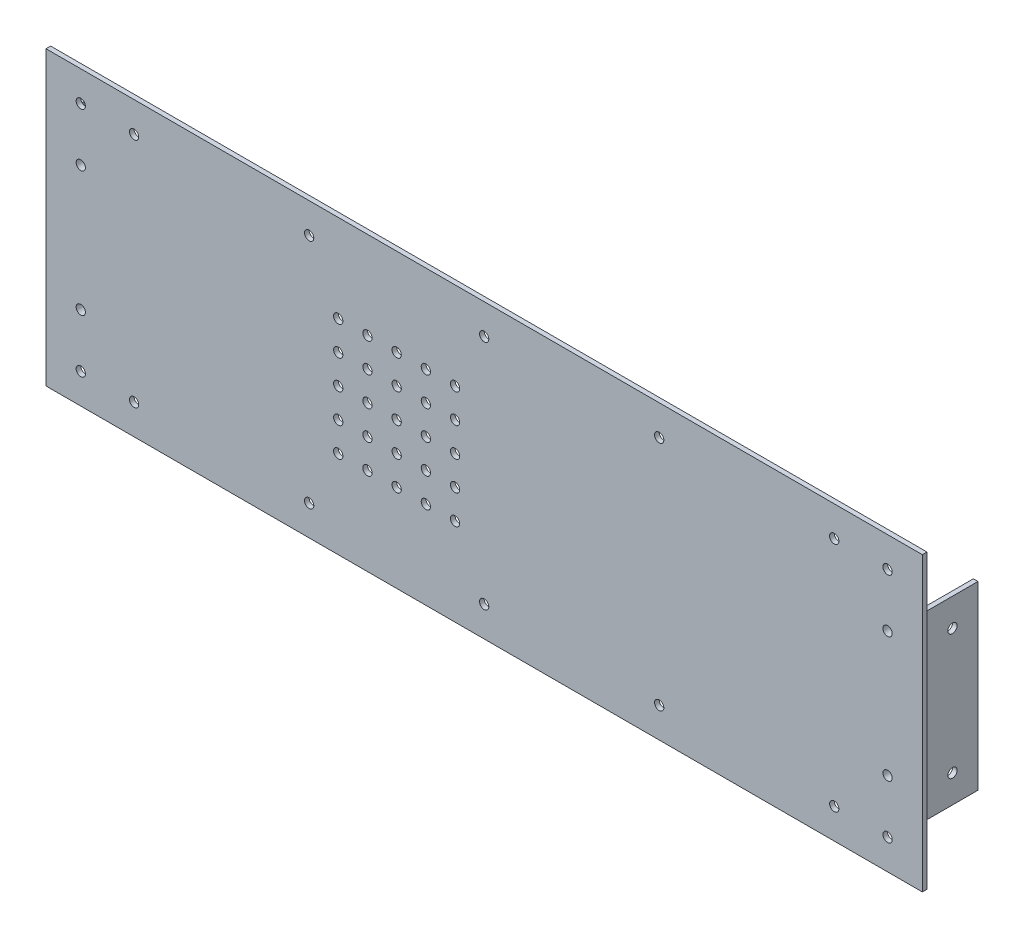
from build123d import *

# Parameters (mm, degrees)
ESQUISSE1_W                  = 300
ESQUISSE1_H                  = 100
BOSS_EXTRU_1_DEPTH           = 1.5875
ESQUISSE2_W                  = 19.05
ESQUISSE2_H                  = 61.9
BOSS_EXTRU_2_DEPTH           = 1.5875
ESQUISSE3_W                  = 1.5875
ESQUISSE3_H                  = 61.9
BOSS_EXTRU_3_DEPTH           = 17.4625
ENL_V_MAT_EXTRU_1_REACH      = 5.175
ESQUISSE4_R                  = 1.5875
ENL_V_MAT_EXTRU_2_REACH      = 22.637
ESQUISSE5_R                  = 1.5875
ESQUISSE7_R                  = 1.5875
ENL_V_MAT_EXTRU_4_DEPTH      = 297.825
ENL_V_MAT_EXTRU_4_DEPTH_BACK = 4.175
ESQUISSE8_R                  = 1.5875
ENL_V_MAT_EXTRU_5_DEPTH      = 1.5875


with BuildPart() as part:
    # Esquisse1 → Boss.-Extru.1 (new body)
    with BuildSketch(Plane.XY):
        with Locations((29.89832913, 31.147540984)):
            Rectangle(ESQUISSE1_W, ESQUISSE1_H)
    extrude(amount=BOSS_EXTRU_1_DEPTH)

    # Esquisse2 → Boss.-Extru.2 (add)
    with BuildSketch(Plane(origin=(0, 0, 0), x_dir=(-1, 0, 0), z_dir=(0, 0, -1))):
        with Locations((108.98917087, 31.147540984)):
            Rectangle(ESQUISSE2_W, ESQUISSE2_H)
        with Locations((-168.78582913, 31.147540984)):
            Rectangle(ESQUISSE2_W, ESQUISSE2_H)
    extrude(amount=BOSS_EXTRU_2_DEPTH)

    # Esquisse3 → Boss.-Extru.3 (add)
    with BuildSketch(Plane(origin=(0, 0, -1.5875), x_dir=(-1, 0, 0), z_dir=(0, 0, -1))):
        with Locations((-177.51707913, 31.147540984)):
            Rectangle(ESQUISSE3_W, ESQUISSE3_H)
        with Locations((117.72042087, 31.147540984)):
            Rectangle(ESQUISSE3_W, ESQUISSE3_H)
    extrude(amount=BOSS_EXTRU_3_DEPTH)

    # Esquisse4 → Enlèv. mat.-Extru.1 (cut, up to next)
    with BuildSketch(Plane(origin=(0, 0, -1.5875), x_dir=(-1, 0, 0), z_dir=(0, 0, -1)), mode=Mode.PRIVATE) as enl_v_mat_extru_1_sk1:
        with Locations((-167.99207913, 52.572540984)):
            Circle(ESQUISSE4_R)
    enl_v_mat_extru_1_tool1 = extrude(enl_v_mat_extru_1_sk1.sketch, amount=-ENL_V_MAT_EXTRU_1_REACH, mode=Mode.PRIVATE) & part.part
    add(enl_v_mat_extru_1_tool1.solids().sort_by_distance((167.992079, 52.572541, -1.5875))[0], mode=Mode.SUBTRACT)
    # Esquisse4 → Enlèv. mat.-Extru.1 (cut, up to next)
    with BuildSketch(Plane(origin=(0, 0, -1.5875), x_dir=(-1, 0, 0), z_dir=(0, 0, -1)), mode=Mode.PRIVATE) as enl_v_mat_extru_1_sk2:
        with Locations((-167.99207913, 9.722540984)):
            Circle(ESQUISSE4_R)
    enl_v_mat_extru_1_tool2 = extrude(enl_v_mat_extru_1_sk2.sketch, amount=-ENL_V_MAT_EXTRU_1_REACH, mode=Mode.PRIVATE) & part.part
    add(enl_v_mat_extru_1_tool2.solids().sort_by_distance((167.992079, 9.722541, -1.5875))[0], mode=Mode.SUBTRACT)
    # Esquisse4 → Enlèv. mat.-Extru.1 (cut, up to next)
    with BuildSketch(Plane(origin=(0, 0, -1.5875), x_dir=(-1, 0, 0), z_dir=(0, 0, -1)), mode=Mode.PRIVATE) as enl_v_mat_extru_1_sk3:
        with Locations((108.19542087, 52.572540984)):
            Circle(ESQUISSE4_R)
    enl_v_mat_extru_1_tool3 = extrude(enl_v_mat_extru_1_sk3.sketch, amount=-ENL_V_MAT_EXTRU_1_REACH, mode=Mode.PRIVATE) & part.part
    add(enl_v_mat_extru_1_tool3.solids().sort_by_distance((-108.195421, 52.572541, -1.5875))[0], mode=Mode.SUBTRACT)
    # Esquisse4 → Enlèv. mat.-Extru.1 (cut, up to next)
    with BuildSketch(Plane(origin=(0, 0, -1.5875), x_dir=(-1, 0, 0), z_dir=(0, 0, -1)), mode=Mode.PRIVATE) as enl_v_mat_extru_1_sk4:
        with Locations((108.19542087, 9.722540984)):
            Circle(ESQUISSE4_R)
    enl_v_mat_extru_1_tool4 = extrude(enl_v_mat_extru_1_sk4.sketch, amount=-ENL_V_MAT_EXTRU_1_REACH, mode=Mode.PRIVATE) & part.part
    add(enl_v_mat_extru_1_tool4.solids().sort_by_distance((-108.195421, 9.722541, -1.5875))[0], mode=Mode.SUBTRACT)

    # Esquisse5 → Enlèv. mat.-Extru.2 (cut, up to next)
    with BuildSketch(Plane.XY.offset(1.5875), mode=Mode.PRIVATE) as enl_v_mat_extru_2_sk1:
        with Locations((-108.19542087, -8.533709016)):
            Circle(ESQUISSE5_R)
    enl_v_mat_extru_2_tool1 = extrude(enl_v_mat_extru_2_sk1.sketch, amount=-ENL_V_MAT_EXTRU_2_REACH, mode=Mode.PRIVATE) & part.part
    add(enl_v_mat_extru_2_tool1.solids().sort_by_distance((-108.195421, -8.533709, 1.5875))[0], mode=Mode.SUBTRACT)
    # Esquisse5 → Enlèv. mat.-Extru.2 (cut, up to next)
    with BuildSketch(Plane.XY.offset(1.5875), mode=Mode.PRIVATE) as enl_v_mat_extru_2_sk2:
        with Locations((-89.93917087, -8.533709016)):
            Circle(ESQUISSE5_R)
    enl_v_mat_extru_2_tool2 = extrude(enl_v_mat_extru_2_sk2.sketch, amount=-ENL_V_MAT_EXTRU_2_REACH, mode=Mode.PRIVATE) & part.part
    add(enl_v_mat_extru_2_tool2.solids().sort_by_distance((-89.939171, -8.533709, 1.5875))[0], mode=Mode.SUBTRACT)
    # Esquisse5 → Enlèv. mat.-Extru.2 (cut, up to next)
    with BuildSketch(Plane.XY.offset(1.5875), mode=Mode.PRIVATE) as enl_v_mat_extru_2_sk3:
        with Locations((-30.02042087, -8.533709016)):
            Circle(ESQUISSE5_R)
    enl_v_mat_extru_2_tool3 = extrude(enl_v_mat_extru_2_sk3.sketch, amount=-ENL_V_MAT_EXTRU_2_REACH, mode=Mode.PRIVATE) & part.part
    add(enl_v_mat_extru_2_tool3.solids().sort_by_distance((-30.020421, -8.533709, 1.5875))[0], mode=Mode.SUBTRACT)
    # Esquisse5 → Enlèv. mat.-Extru.2 (cut, up to next)
    with BuildSketch(Plane.XY.offset(1.5875), mode=Mode.PRIVATE) as enl_v_mat_extru_2_sk4:
        with Locations((29.89832913, -8.533709016)):
            Circle(ESQUISSE5_R)
    enl_v_mat_extru_2_tool4 = extrude(enl_v_mat_extru_2_sk4.sketch, amount=-ENL_V_MAT_EXTRU_2_REACH, mode=Mode.PRIVATE) & part.part
    add(enl_v_mat_extru_2_tool4.solids().sort_by_distance((29.898329, -8.533709, 1.5875))[0], mode=Mode.SUBTRACT)
    # Esquisse5 → Enlèv. mat.-Extru.2 (cut, up to next)
    with BuildSketch(Plane.XY.offset(1.5875), mode=Mode.PRIVATE) as enl_v_mat_extru_2_sk5:
        with Locations((89.81707913, -8.533709016)):
            Circle(ESQUISSE5_R)
    enl_v_mat_extru_2_tool5 = extrude(enl_v_mat_extru_2_sk5.sketch, amount=-ENL_V_MAT_EXTRU_2_REACH, mode=Mode.PRIVATE) & part.part
    add(enl_v_mat_extru_2_tool5.solids().sort_by_distance((89.817079, -8.533709, 1.5875))[0], mode=Mode.SUBTRACT)
    # Esquisse5 → Enlèv. mat.-Extru.2 (cut, up to next)
    with BuildSketch(Plane.XY.offset(1.5875), mode=Mode.PRIVATE) as enl_v_mat_extru_2_sk6:
        with Locations((149.73582913, -8.533709016)):
            Circle(ESQUISSE5_R)
    enl_v_mat_extru_2_tool6 = extrude(enl_v_mat_extru_2_sk6.sketch, amount=-ENL_V_MAT_EXTRU_2_REACH, mode=Mode.PRIVATE) & part.part
    add(enl_v_mat_extru_2_tool6.solids().sort_by_distance((149.735829, -8.533709, 1.5875))[0], mode=Mode.SUBTRACT)
    # Esquisse5 → Enlèv. mat.-Extru.2 (cut, up to next)
    with BuildSketch(Plane.XY.offset(1.5875), mode=Mode.PRIVATE) as enl_v_mat_extru_2_sk7:
        with Locations((167.99207913, -8.533709016)):
            Circle(ESQUISSE5_R)
    enl_v_mat_extru_2_tool7 = extrude(enl_v_mat_extru_2_sk7.sketch, amount=-ENL_V_MAT_EXTRU_2_REACH, mode=Mode.PRIVATE) & part.part
    add(enl_v_mat_extru_2_tool7.solids().sort_by_distance((167.992079, -8.533709, 1.5875))[0], mode=Mode.SUBTRACT)
    # Esquisse5 → Enlèv. mat.-Extru.2 (cut, up to next)
    with BuildSketch(Plane.XY.offset(1.5875), mode=Mode.PRIVATE) as enl_v_mat_extru_2_sk8:
        with Locations((167.99207913, 70.828790984)):
            Circle(ESQUISSE5_R)
    enl_v_mat_extru_2_tool8 = extrude(enl_v_mat_extru_2_sk8.sketch, amount=-ENL_V_MAT_EXTRU_2_REACH, mode=Mode.PRIVATE) & part.part
    add(enl_v_mat_extru_2_tool8.solids().sort_by_distance((167.992079, 70.828791, 1.5875))[0], mode=Mode.SUBTRACT)
    # Esquisse5 → Enlèv. mat.-Extru.2 (cut, up to next)
    with BuildSketch(Plane.XY.offset(1.5875), mode=Mode.PRIVATE) as enl_v_mat_extru_2_sk9:
        with Locations((149.73582913, 70.828790984)):
            Circle(ESQUISSE5_R)
    enl_v_mat_extru_2_tool9 = extrude(enl_v_mat_extru_2_sk9.sketch, amount=-ENL_V_MAT_EXTRU_2_REACH, mode=Mode.PRIVATE) & part.part
    add(enl_v_mat_extru_2_tool9.solids().sort_by_distance((149.735829, 70.828791, 1.5875))[0], mode=Mode.SUBTRACT)
    # Esquisse5 → Enlèv. mat.-Extru.2 (cut, up to next)
    with BuildSketch(Plane.XY.offset(1.5875), mode=Mode.PRIVATE) as enl_v_mat_extru_2_sk10:
        with Locations((89.81707913, 70.828790984)):
            Circle(ESQUISSE5_R)
    enl_v_mat_extru_2_tool10 = extrude(enl_v_mat_extru_2_sk10.sketch, amount=-ENL_V_MAT_EXTRU_2_REACH, mode=Mode.PRIVATE) & part.part
    add(enl_v_mat_extru_2_tool10.solids().sort_by_distance((89.817079, 70.828791, 1.5875))[0], mode=Mode.SUBTRACT)
    # Esquisse5 → Enlèv. mat.-Extru.2 (cut, up to next)
    with BuildSketch(Plane.XY.offset(1.5875), mode=Mode.PRIVATE) as enl_v_mat_extru_2_sk11:
        with Locations((29.89832913, 70.828790984)):
            Circle(ESQUISSE5_R)
    enl_v_mat_extru_2_tool11 = extrude(enl_v_mat_extru_2_sk11.sketch, amount=-ENL_V_MAT_EXTRU_2_REACH, mode=Mode.PRIVATE) & part.part
    add(enl_v_mat_extru_2_tool11.solids().sort_by_distance((29.898329, 70.828791, 1.5875))[0], mode=Mode.SUBTRACT)
    # Esquisse5 → Enlèv. mat.-Extru.2 (cut, up to next)
    with BuildSketch(Plane.XY.offset(1.5875), mode=Mode.PRIVATE) as enl_v_mat_extru_2_sk12:
        with Locations((-30.02042087, 70.828790984)):
            Circle(ESQUISSE5_R)
    enl_v_mat_extru_2_tool12 = extrude(enl_v_mat_extru_2_sk12.sketch, amount=-ENL_V_MAT_EXTRU_2_REACH, mode=Mode.PRIVATE) & part.part
    add(enl_v_mat_extru_2_tool12.solids().sort_by_distance((-30.020421, 70.828791, 1.5875))[0], mode=Mode.SUBTRACT)
    # Esquisse5 → Enlèv. mat.-Extru.2 (cut, up to next)
    with BuildSketch(Plane.XY.offset(1.5875), mode=Mode.PRIVATE) as enl_v_mat_extru_2_sk13:
        with Locations((-89.93917087, 70.828790984)):
            Circle(ESQUISSE5_R)
    enl_v_mat_extru_2_tool13 = extrude(enl_v_mat_extru_2_sk13.sketch, amount=-ENL_V_MAT_EXTRU_2_REACH, mode=Mode.PRIVATE) & part.part
    add(enl_v_mat_extru_2_tool13.solids().sort_by_distance((-89.939171, 70.828791, 1.5875))[0], mode=Mode.SUBTRACT)
    # Esquisse5 → Enlèv. mat.-Extru.2 (cut, up to next)
    with BuildSketch(Plane.XY.offset(1.5875), mode=Mode.PRIVATE) as enl_v_mat_extru_2_sk14:
        with Locations((-108.19542087, 70.828790984)):
            Circle(ESQUISSE5_R)
    enl_v_mat_extru_2_tool14 = extrude(enl_v_mat_extru_2_sk14.sketch, amount=-ENL_V_MAT_EXTRU_2_REACH, mode=Mode.PRIVATE) & part.part
    add(enl_v_mat_extru_2_tool14.solids().sort_by_distance((-108.195421, 70.828791, 1.5875))[0], mode=Mode.SUBTRACT)

    # Esquisse7 → Enlèv. mat.-Extru.4 (cut, two sides)
    with BuildSketch(Plane.ZY.offset(-176.72332913)) as enl_v_mat_extru_4_sk:
        with Locations((-10.31875, 52.572540984)):
            Circle(ESQUISSE7_R)
        with Locations((-10.31875, 9.722540984)):
            Circle(ESQUISSE7_R)
    extrude(amount=ENL_V_MAT_EXTRU_4_DEPTH, mode=Mode.SUBTRACT)
    extrude(enl_v_mat_extru_4_sk.sketch, amount=-ENL_V_MAT_EXTRU_4_DEPTH_BACK, mode=Mode.SUBTRACT)

    # Esquisse8 → Enlèv. mat.-Extru.5 (cut)
    with BuildSketch(Plane.XY.offset(1.5875)):
        with Locations((-20.06104587, 11.147540984)):
            Circle(ESQUISSE8_R)
        with Locations((-10.06104587, 11.147540984)):
            Circle(ESQUISSE8_R)
        with Locations((-0.06104587, 11.147540984)):
            Circle(ESQUISSE8_R)
        with Locations((9.93895413, 11.147540984)):
            Circle(ESQUISSE8_R)
        with Locations((19.93895413, 11.147540984)):
            Circle(ESQUISSE8_R)
        with Locations((-10.06104587, 21.147540984)):
            Circle(ESQUISSE8_R)
        with Locations((-0.06104587, 21.147540984)):
            Circle(ESQUISSE8_R)
        with Locations((9.93895413, 21.147540984)):
            Circle(ESQUISSE8_R)
        with Locations((19.93895413, 21.147540984)):
            Circle(ESQUISSE8_R)
        with Locations((-10.06104587, 31.147540984)):
            Circle(ESQUISSE8_R)
        with Locations((-0.06104587, 31.147540984)):
            Circle(ESQUISSE8_R)
        with Locations((9.93895413, 31.147540984)):
            Circle(ESQUISSE8_R)
        with Locations((19.93895413, 31.147540984)):
            Circle(ESQUISSE8_R)
        with Locations((-10.06104587, 41.147540984)):
            Circle(ESQUISSE8_R)
        with Locations((-0.06104587, 41.147540984)):
            Circle(ESQUISSE8_R)
        with Locations((9.93895413, 41.147540984)):
            Circle(ESQUISSE8_R)
        with Locations((19.93895413, 41.147540984)):
            Circle(ESQUISSE8_R)
        with Locations((-10.06104587, 51.147540984)):
            Circle(ESQUISSE8_R)
        with Locations((-0.06104587, 51.147540984)):
            Circle(ESQUISSE8_R)
        with Locations((9.93895413, 51.147540984)):
            Circle(ESQUISSE8_R)
        with Locations((19.93895413, 51.147540984)):
            Circle(ESQUISSE8_R)
        with Locations((-20.06104587, 21.147540984)):
            Circle(ESQUISSE8_R)
        with Locations((-20.06104587, 31.147540984)):
            Circle(ESQUISSE8_R)
        with Locations((-20.06104587, 41.147540984)):
            Circle(ESQUISSE8_R)
        with Locations((-20.06104587, 51.147540984)):
            Circle(ESQUISSE8_R)
    extrude(amount=-ENL_V_MAT_EXTRU_5_DEPTH, mode=Mode.SUBTRACT)


solid = part.part
